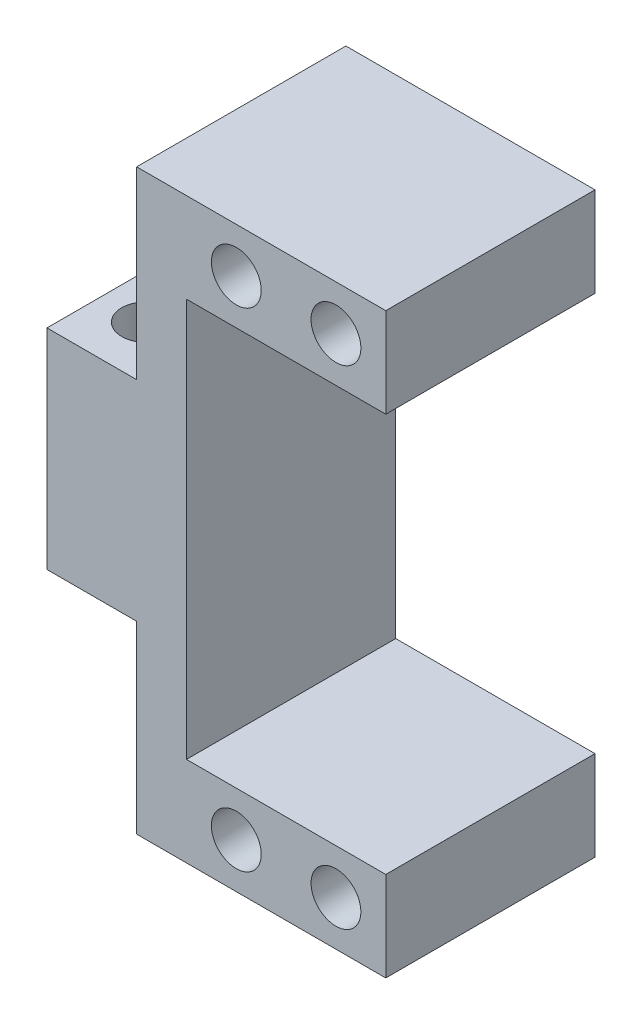
from build123d import *

# Parameters (mm, degrees)
EXTRUSION1_DEPTH        = 21
ESQUISSE2_R             = 2.5
ENL_V_MAT_EXTRU_1_DEPTH = 22
ESQUISSE3_R             = 2.5
ENL_V_MAT_EXTRU_2_DEPTH = 40.5


with BuildPart() as part:
    # Esquisse1 → Extrusion1 (new body)
    with BuildSketch(Plane.XY):
        Polygon((0, -10.5), (0, 10.5), (9, 10.5), (9, 29), (34, 29), (34, 20), (14, 20), (14, -20), (34, -20), (34, -29), (9, -29), (9, -10.5), align=None)
    extrude(amount=EXTRUSION1_DEPTH)

    # Esquisse2 → Enlèv. mat.-Extru.1 (cut, through all)
    with BuildSketch(Plane.XY.offset(21)):
        with Locations((29, 24.5)):
            Circle(ESQUISSE2_R)
        with Locations((19, 24.5)):
            Circle(ESQUISSE2_R)
        with Locations((19, -24.5)):
            Circle(ESQUISSE2_R)
        with Locations((29, -24.5)):
            Circle(ESQUISSE2_R)
    extrude(amount=-ENL_V_MAT_EXTRU_1_DEPTH, mode=Mode.SUBTRACT)

    # Esquisse3 → Enlèv. mat.-Extru.2 (cut, through all)
    with BuildSketch(Plane(origin=(0, 10.5, 0), x_dir=(1, 0, 0), z_dir=(0, 1, 0))):
        with Locations((4.5, -5.5)):
            Circle(ESQUISSE3_R)
        with Locations((4.5, -15.5)):
            Circle(ESQUISSE3_R)
    extrude(amount=-ENL_V_MAT_EXTRU_2_DEPTH, mode=Mode.SUBTRACT)


solid = part.part
